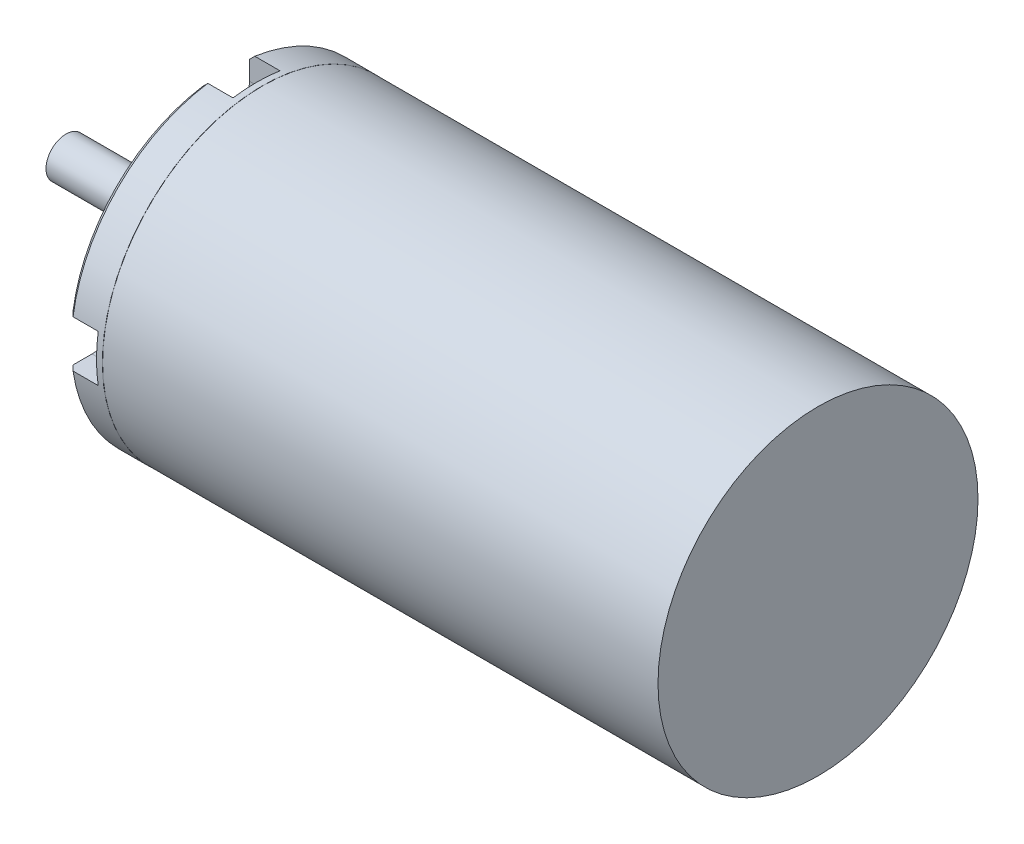
from build123d import *

# Parameters (mm, degrees)
SKETCH1_R                       = 20
BOSS_EXTRUDE1_DEPTH             = 74
SKETCH2_R                       = 2.5
BOSS_EXTRUDE2_DEPTH             = 20
BOSS_EXTRUDE2_DIRECTION_2_REACH = 76
CUT_EXTRUDE1_DEPTH              = 3.81
SKETCH7_R                       = 1.526021313
CUT_EXTRUDE2_DEPTH              = 8.89


with BuildPart() as part:
    # Sketch1 → Boss-Extrude1 (new body)
    with BuildSketch(Plane(origin=(0, 0, 0), x_dir=(0, 0, -1), z_dir=(1, 0, 0))):
        Circle(SKETCH1_R)
    extrude(amount=BOSS_EXTRUDE1_DEPTH)

    # Sketch5 → Cut-Revolve1 (revolve, cut)
    with BuildSketch(Plane(origin=(0, 0, 0), x_dir=(1, 0, 0), z_dir=(0, 1, 0))):
        Polygon((0, 19.337777094), (0.662222906, 20), (0.662222906, 20.176229402), (4.550138216, 20.176229402), (4.550138216, 19.930023338), (4.572872876, 19.930023338), (4.572872876, 20.70759824), (0.489891522, 20.70759824), (-0.879929624, 19.337777094), align=None)
        Polygon((0, 0), (0.645058213, 0), (0.645058213, 3.416287186), (0.081805863, 3.416287186), (0, 3.498093049), (-0.347704824, 3.498093049), (-0.347704824, 0), align=None)
    revolve(axis=Axis((-44.161448521, 0, 0), (1, 0, 0)), mode=Mode.SUBTRACT)

    # Sketch2 → Boss-Extrude2 (add)
    with BuildSketch(Plane.ZY):
        Circle(SKETCH2_R)
    extrude(amount=BOSS_EXTRUDE2_DEPTH)

    # Sketch2 → Boss-Extrude2 direction 2 (add, up to next)
    with BuildSketch(Plane.ZY, mode=Mode.PRIVATE) as boss_extrude2_direction_2_sk1:
        Circle(SKETCH2_R)
    boss_extrude2_direction_2_tool1 = extrude(boss_extrude2_direction_2_sk1.sketch, amount=-BOSS_EXTRUDE2_DIRECTION_2_REACH, mode=Mode.PRIVATE) - part.part
    add(boss_extrude2_direction_2_tool1.solids().sort_by_distance((0, 0, 0))[0])

    # Sketch6 → Cut-Extrude1 (cut)
    with BuildSketch(Plane.ZY):
        with BuildLine():
            Line((-2.93474373, 16.742014233), (-2.93474373, 20.766805635))
            Line((-2.93474373, 20.766805635), (2.93474373, 20.766805635))
            Line((2.93474373, 20.766805635), (2.93474373, 16.742014233))
            ThreePointArc((2.93474373, 16.742014233), (0, 13.807270503), (-2.93474373, 16.742014233))
        make_face()
        with BuildLine():
            Line((20.766805635, -2.93474373), (16.742014233, -2.93474373))
            ThreePointArc((16.742014233, -2.93474373), (13.807270503, 0), (16.742014233, 2.93474373))
            Line((16.742014233, 2.93474373), (20.766805635, 2.93474373))
            Line((20.766805635, 2.93474373), (20.766805635, -2.93474373))
        make_face()
        with BuildLine():
            Line((-2.93474373, -20.766805635), (-2.93474373, -16.742014233))
            ThreePointArc((-2.93474373, -16.742014233), (0, -13.807270503), (2.93474373, -16.742014233))
            Line((2.93474373, -16.742014233), (2.93474373, -20.766805635))
            Line((2.93474373, -20.766805635), (-2.93474373, -20.766805635))
        make_face()
        with BuildLine():
            Line((-20.766805635, 2.93474373), (-16.742014233, 2.93474373))
            ThreePointArc((-16.742014233, 2.93474373), (-13.807270503, 0), (-16.742014233, -2.93474373))
            Line((-16.742014233, -2.93474373), (-20.766805635, -2.93474373))
            Line((-20.766805635, -2.93474373), (-20.766805635, 2.93474373))
        make_face()
    extrude(amount=-CUT_EXTRUDE1_DEPTH, mode=Mode.SUBTRACT)

    # Sketch7 → Cut-Extrude2 (cut)
    with BuildSketch(Plane.ZY):
        with Locations((-3.398071731, 12.681776348)):
            Circle(SKETCH7_R)
        with Locations((9.283704617, 9.283704617)):
            Circle(SKETCH7_R)
        with Locations((12.681776348, -3.398071731)):
            Circle(SKETCH7_R)
        with Locations((3.398071731, -12.681776348)):
            Circle(SKETCH7_R)
        with Locations((-9.283704617, -9.283704617)):
            Circle(SKETCH7_R)
        with Locations((-12.681776348, 3.398071731)):
            Circle(SKETCH7_R)
    extrude(amount=-CUT_EXTRUDE2_DEPTH, mode=Mode.SUBTRACT)


solid = part.part
